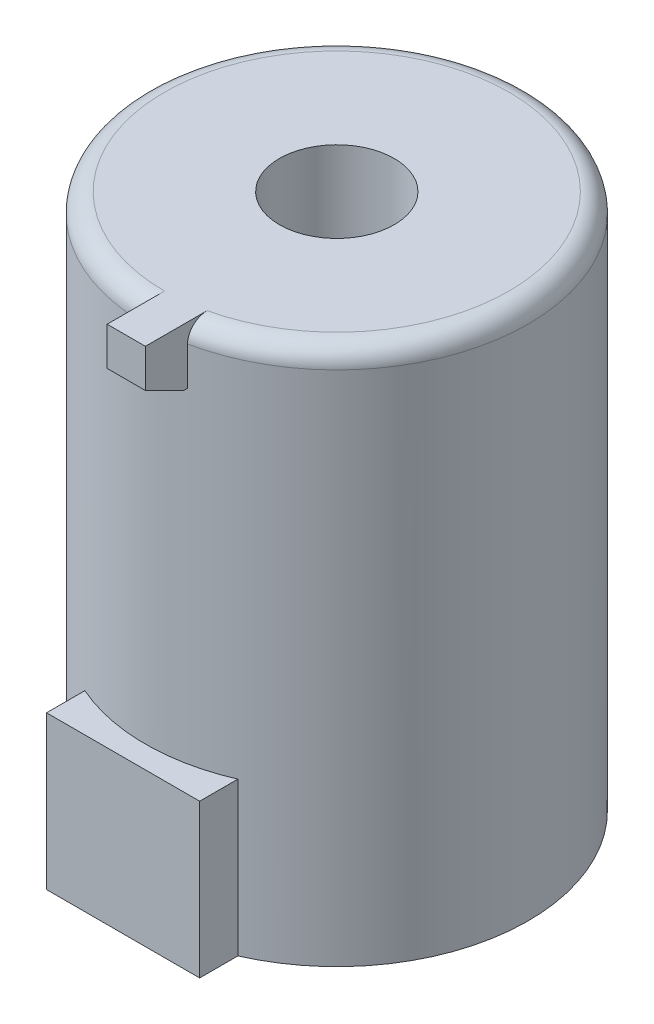
from build123d import *

# Parameters (mm, degrees)
SKETCH_1_R          = 50
EXTRUDE_1_DEPTH     = 140
SKETCH_2_W          = 40
SKETCH_2_H          = 10
EXTRUDE_2_DEPTH     = 40
SKETCH_3_R          = 15
CUT_EXTRUDE_1_DEPTH = 40
EXTRUDE_4_DEPTH     = 10
FILLET_2_R          = 5


with BuildPart() as part:
    # 草圖1 → 填料-伸長1 (new body)
    with BuildSketch(Plane(origin=(0, 0, 0), x_dir=(1, 0, 0), z_dir=(0, 1, 0))):
        with Locations(Location((0, 0, 0), (0, 0, 270))):
            Circle(SKETCH_1_R)
    extrude(amount=EXTRUDE_1_DEPTH)

    # 草圖2 → 填料-伸長2 (add)
    with BuildSketch(Plane.XZ):
        with Locations((0, 50.82575695)):
            Rectangle(SKETCH_2_W, SKETCH_2_H)
    extrude(amount=-EXTRUDE_2_DEPTH)

    # 草圖3 → 除料-伸長1 (cut)
    with BuildSketch(Plane(origin=(0, 140, 0), x_dir=(1, 0, 0), z_dir=(0, 1, 0))):
        with Locations(Location((0, 0, 0), (0, 0, 270))):
            Circle(SKETCH_3_R)
    extrude(amount=-CUT_EXTRUDE_1_DEPTH, mode=Mode.SUBTRACT)

    # 草圖4 → 填料-伸長4 (add)
    with BuildSketch(Plane(origin=(0, 0, 0), x_dir=(0, 0, -1), z_dir=(1, 0, 0))):
        Polygon((-50, 140), (-60, 140), (-60, 130), (-50, 125), (-44.587553404, 125), (-44.587553404, 140), align=None)
    extrude(amount=EXTRUDE_4_DEPTH)

    # 圓角2
    fillet_2_edges = [part.edges().sort_by_distance(p)[0] for p in [
        (-5.0254481, 140, -49.74680765),
    ]]
    fillet(fillet_2_edges, radius=FILLET_2_R)


solid = part.part
